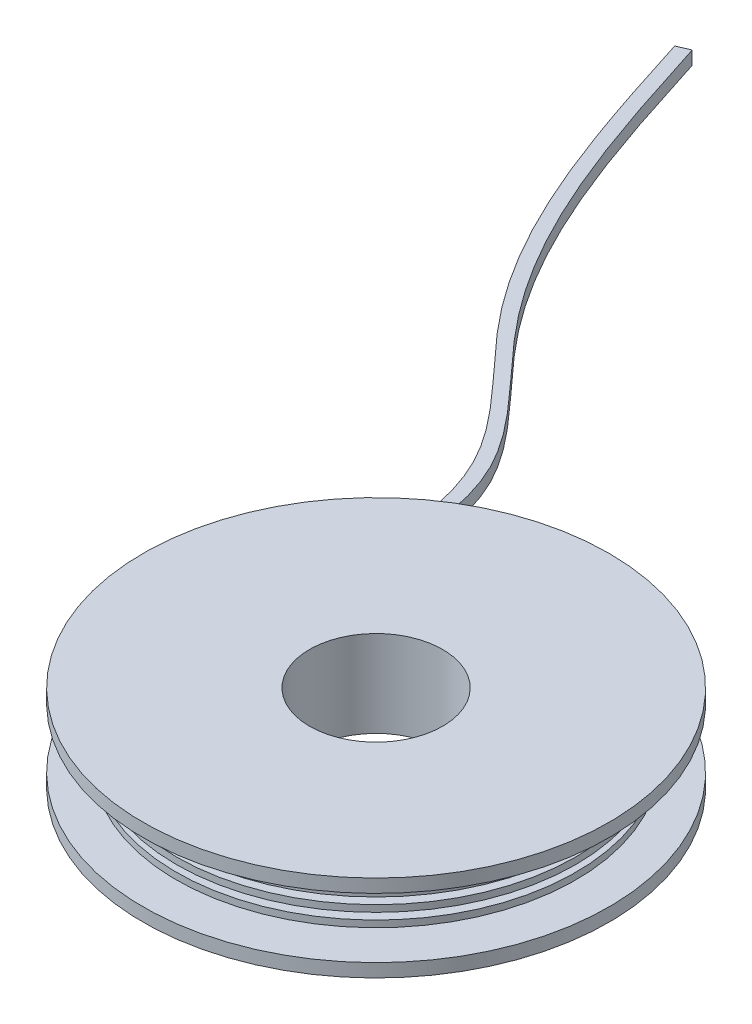
from build123d import *

# Parameters (mm, degrees)
LINEAR_AUSTRAGEN1_DEPTH      = 1
LINEAR_AUSTRAGEN1_DEPTH_BACK = 1
SKIZZE6_R                    = 10
LINEAR_AUSTRAGEN2_DEPTH      = 14


with BuildPart() as part:
    # Skizze2 → Rotation1 (revolve)
    with BuildSketch(Plane.XY, mode=Mode.PRIVATE) as rotation1_sk:
        Polygon((0, 0), (35, 0), (35, 2), (25, 2), (25, 3), (30, 3), (30, 4), (25, 4), (25, 5), (30, 5), (30, 6), (25, 6), (25, 7), (30, 7), (30, 8), (25, 8), (25, 9), (30, 9), (30, 10), (25, 10), (25, 11), (35, 11), (35, 13), (0, 13), align=None)
    revolve(rotation1_sk.sketch.rotate(Axis((0, 0, 0), (0, 1, 0)), 90), axis=Axis((0, 0, 0), (0, 1, 0)))  # turned: the seam where the file's is

    # Skizze5 → Linear austragen1 (add, two sides)
    with BuildSketch(Plane.XZ.offset(-3)) as linear_austragen1_sk:
        with BuildLine():
            Line((-27.327200212, -12.378373422), (-29.327200212, -6.317857842))
            add(Edge.make_bspline(
                [(-29.327200212, -6.317857842), (-27.376461725, -20.505117436), (-24.179519663, -43.75572085), (-56.295044405, -71.57330883), (-64.478459695, -97.327806995), (-70.069385578, -114.923332251)],
                knots=[0, 0, 0, 0, 0.331505275, 0.543283051, 1, 1, 1, 1], degree=3))
            Line((-70.069385578, -114.923332251), (-68.234927057, -115.720051735))
            add(Edge.make_bspline(
                [(-27.327200212, -12.378373422), (-25.584010264, -25.096675338), (-23.311002372, -45.18830878), (-54.519049761, -72.525658101), (-62.667731325, -98.187695715), (-68.234927057, -115.720051735)],
                knots=[0, 0, 0, 0, 0.308292386, 0.527423959, 1, 1, 1, 1], degree=3))
        make_face()
    extrude(amount=LINEAR_AUSTRAGEN1_DEPTH)
    extrude(linear_austragen1_sk.sketch, amount=-LINEAR_AUSTRAGEN1_DEPTH_BACK)

    # Skizze6 → Linear austragen2 (cut, through all)
    with BuildSketch(Plane(origin=(0, 13, 0), x_dir=(1, 0, 0), z_dir=(0, 1, 0))):
        with Locations(Location((0, 0, 0), (0, 0, 270))):  # turned: the seam where the file's is
            Circle(SKIZZE6_R)
    extrude(amount=-LINEAR_AUSTRAGEN2_DEPTH, mode=Mode.SUBTRACT)


solid = part.part
